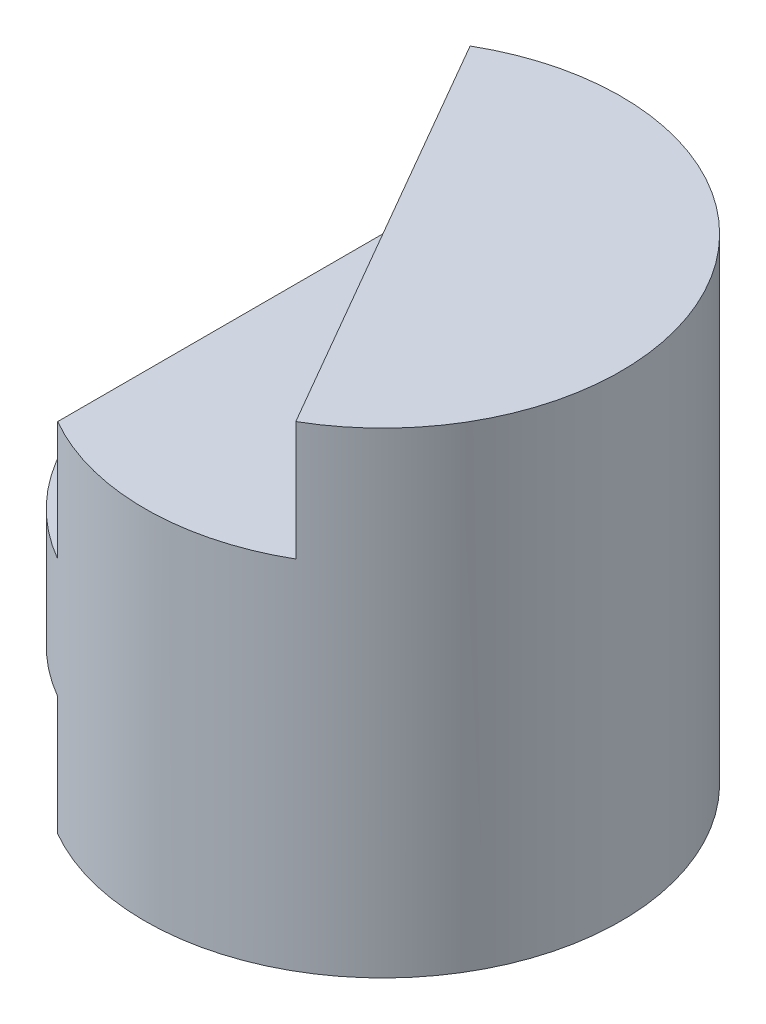
from build123d import *

# Parameters (mm, degrees)
SKETCH1_R               = 2
BOSS_EXTRUDE1_DEPTH     = 4
SKETCH2_W               = 1
SKETCH2_H               = 2
SKETCH2_H_2             = 1
CUT_EXTRUDE1_DEPTH      = 2
CUT_EXTRUDE4_DEPTH      = 1
CUT_EXTRUDE4_DEPTH_BACK = 1


with BuildPart() as part:
    # Sketch1 → Boss-Extrude1 (new body)
    with BuildSketch(Plane(origin=(0, 0, 0), x_dir=(1, 0, 0), z_dir=(0, 1, 0))):
        Circle(SKETCH1_R)
    extrude(amount=BOSS_EXTRUDE1_DEPTH)

    # Sketch2 → Cut-Extrude1 (cut, symmetric)
    with BuildSketch(Plane.XY):
        with Locations((-1.5, 3)):
            Rectangle(SKETCH2_W, SKETCH2_H)
        with Locations((-1.5, 0.5)):
            Rectangle(SKETCH2_W, SKETCH2_H_2)
    extrude(amount=CUT_EXTRUDE1_DEPTH, both=True, mode=Mode.SUBTRACT)

    # Sketch3 → Cut-Extrude4 (cut, two sides)
    with BuildSketch(Plane(origin=(0, 4, 0), x_dir=(1, 0, 0), z_dir=(0, 1, 0))) as cut_extrude4_sk:
        with BuildLine():
            ThreePointArc((-1, -1.732050808), (0, -2), (1, -1.732050808))
            Line((1, -1.732050808), (-1, 1.732050808))
            Line((-1, 1.732050808), (-1, -1.732050808))
        make_face()
    extrude(amount=CUT_EXTRUDE4_DEPTH, mode=Mode.SUBTRACT)
    extrude(cut_extrude4_sk.sketch, amount=-CUT_EXTRUDE4_DEPTH_BACK, mode=Mode.SUBTRACT)


solid = part.part
